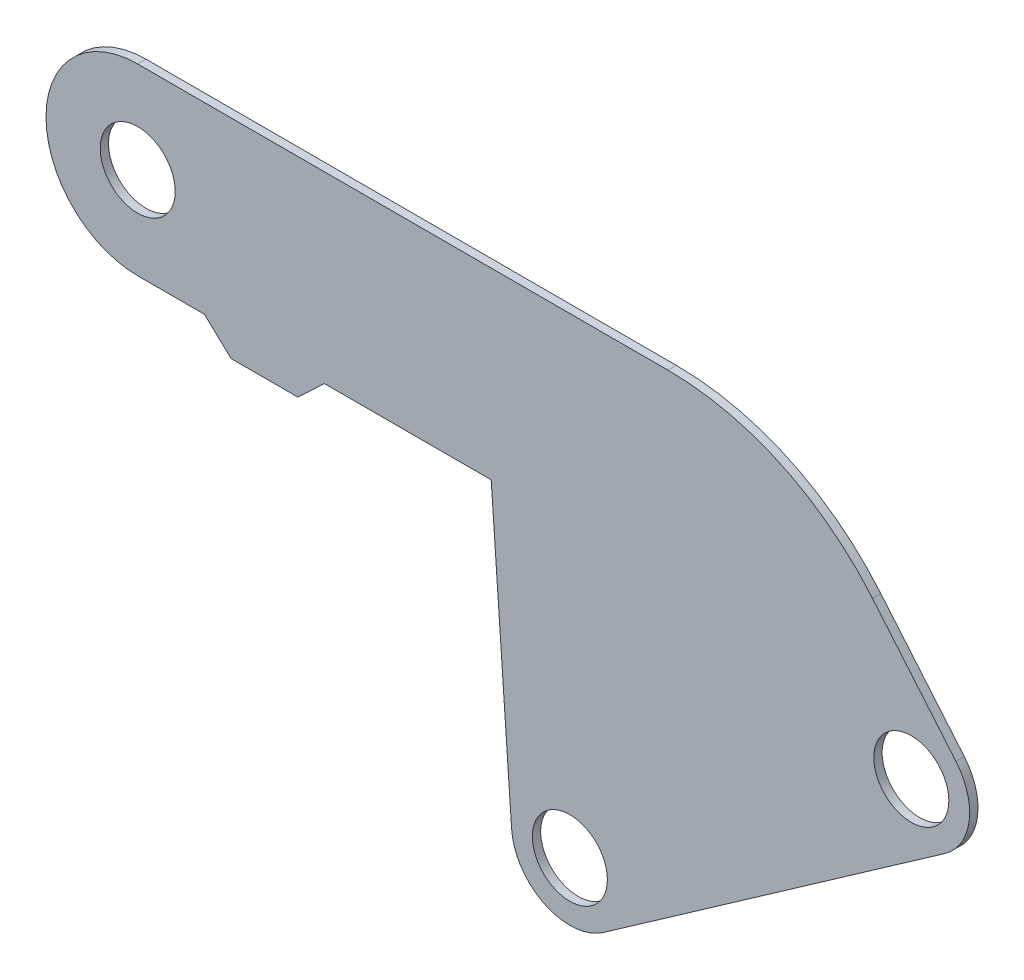
from build123d import *

# Parameters (mm, degrees)
SKETCH1_R           = 14.2875
BOSS_EXTRUDE1_DEPTH = 3.175


with BuildPart() as part:
    # Sketch1 → Boss-Extrude1 (new body)
    with BuildSketch(Plane.XY):
        with BuildLine():
            Line((134.62, 180.975), (142.401211704, 69.698488351))
            ThreePointArc((142.401211704, 69.698488351), (155.003963594, 51.188868036), (177.319809019, 53.043171796))
            Line((177.319809019, 53.043171796), (307.36019605, 144.098431067))
            ThreePointArc((307.36019605, 144.098431067), (316.647321796, 159.403140629), (311.6377975, 176.590039876))
            Line((311.6377975, 176.590039876), (279.800527192, 214.532221144))
            ThreePointArc((279.800527192, 214.532221144), (244.908427164, 241.305871163), (201.970411771, 250.825))
            Line((201.970411771, 250.825), (0, 250.825))
            ThreePointArc((0, 250.825), (-34.925, 215.9), (0, 180.975))
            Line((0, 180.975), (25.4, 180.975))
            Line((25.4, 180.975), (35.56, 171.45))
            Line((35.56, 171.45), (60.96, 171.45))
            Line((60.96, 171.45), (71.12, 180.975))
            Line((71.12, 180.975), (134.62, 180.975))
        make_face()
        with Locations((294.612459752, 162.304085251)):
            Circle(SKETCH1_R, mode=Mode.SUBTRACT)
        with Locations((164.572072721, 71.24882598)):
            Circle(SKETCH1_R, mode=Mode.SUBTRACT)
        with Locations((0, 215.9)):
            Circle(SKETCH1_R, mode=Mode.SUBTRACT)
    extrude(amount=BOSS_EXTRUDE1_DEPTH)


solid = part.part
